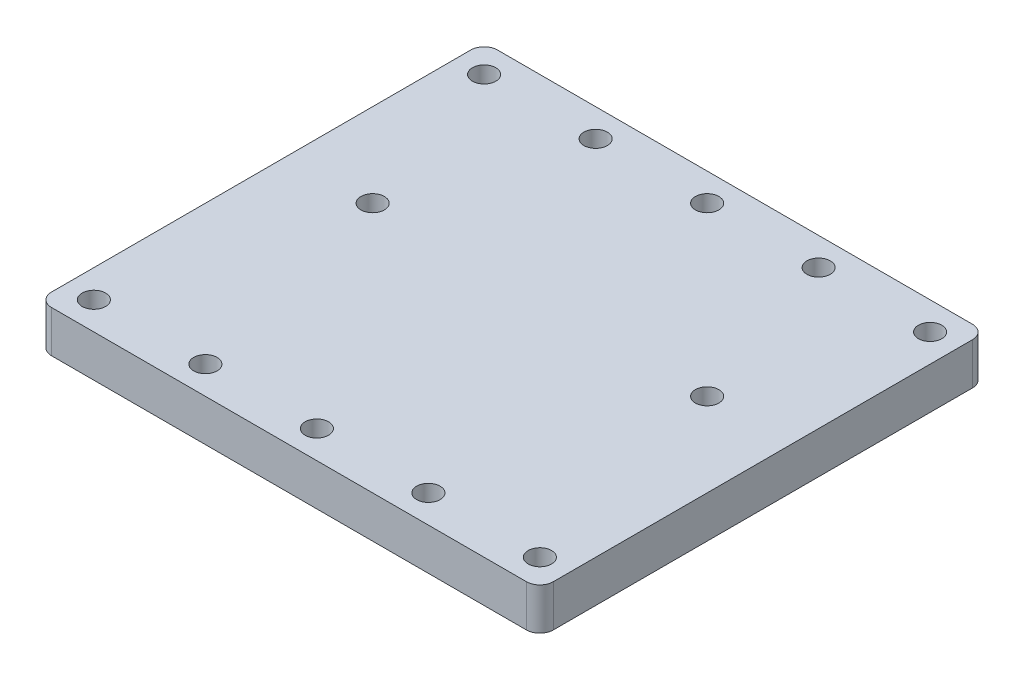
from build123d import *

# Parameters (mm, degrees)
SKETCH1_W           = 114.3
SKETCH1_H           = 101.6
BOSS_EXTRUDE1_DEPTH = 9.525
FILLET1_R           = 3.048
SKETCH3_R           = 2.667
CUT_EXTRUDE1_DEPTH  = 9.525


with BuildPart() as part:
    # Sketch1 → Boss-Extrude1 (new body)
    with BuildSketch(Plane(origin=(0, 0, 0), x_dir=(1, 0, 0), z_dir=(0, 1, 0))):
        Rectangle(SKETCH1_W, SKETCH1_H)
    extrude(amount=BOSS_EXTRUDE1_DEPTH)

    # Fillet1
    fillet1_edges = [part.edges().sort_by_distance(p)[0] for p in [
        (-57.15, 4.7625, -50.8),
        (57.15, 4.7625, -50.8),
        (57.15, 4.7625, 50.8),
        (-57.15, 4.7625, 50.8),
    ]]
    fillet(fillet1_edges, radius=FILLET1_R)

    # Sketch3 → Cut-Extrude1 (cut)
    with BuildSketch(Plane(origin=(0, 9.525, 0), x_dir=(1, 0, 0), z_dir=(0, 1, 0))):
        with Locations((50.8, 44.45)):
            Circle(SKETCH3_R)
        with Locations((25.4, 44.45)):
            Circle(SKETCH3_R)
        with Locations((0, 44.45)):
            Circle(SKETCH3_R)
        with Locations((-25.4, 44.45)):
            Circle(SKETCH3_R)
        with Locations((-50.8, 44.45)):
            Circle(SKETCH3_R)
        with Locations((25.4, -44.45)):
            Circle(SKETCH3_R)
        with Locations((0, -44.45)):
            Circle(SKETCH3_R)
        with Locations((-25.4, -44.45)):
            Circle(SKETCH3_R)
        with Locations((-50.8, -44.45)):
            Circle(SKETCH3_R)
        with Locations((50.8, -44.45)):
            Circle(SKETCH3_R)
        with Locations((38.1, 6.35)):
            Circle(SKETCH3_R)
        with Locations((-38.1, 6.35)):
            Circle(SKETCH3_R)
    extrude(amount=-CUT_EXTRUDE1_DEPTH, mode=Mode.SUBTRACT)


solid = part.part
